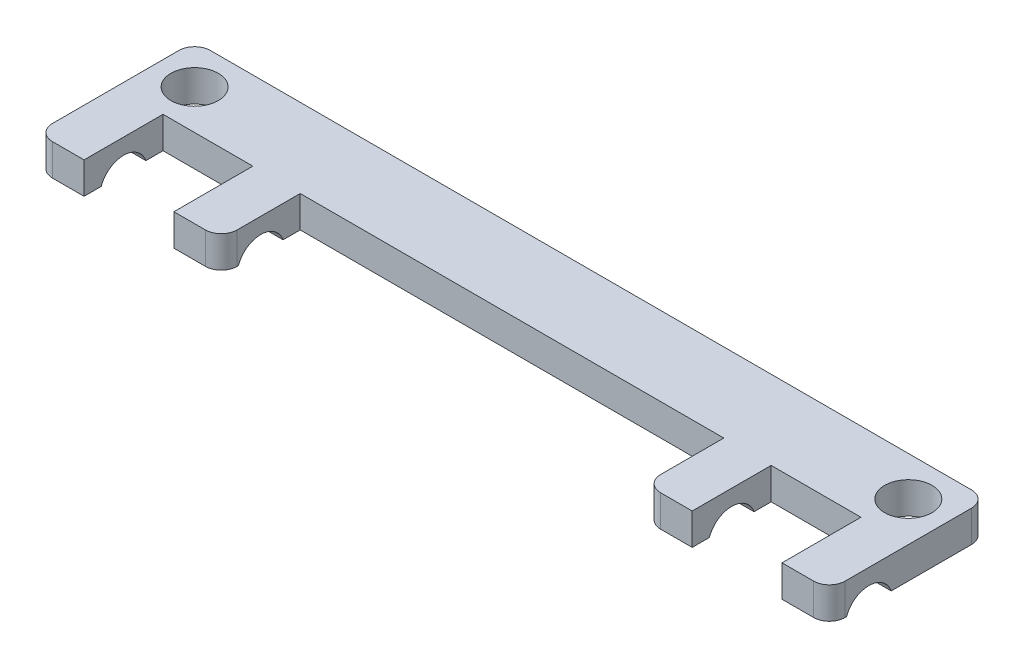
from build123d import *

# Parameters (mm, degrees)
SKETCH1_R           = 1.5
BOSS_EXTRUDE1_DEPTH = 2
SKETCH2_R           = 1.5
CUT_EXTRUDE1_DEPTH  = 55
FILLET1_R           = 1


with BuildPart() as part:
    # Sketch1 → Boss-Extrude1 (new body)
    with BuildSketch(Plane(origin=(0, 0, 0), x_dir=(1, 0, 0), z_dir=(0, 1, 0))):
        Polygon((0, 5), (0, -5), (3, -5), (3, 0), (8.68728571, 0), (8.68728571, -5), (11.68728571, -5), (11.68728571, 0), (38.51271429, 0), (38.51271429, -5), (41.51271429, -5), (41.51271429, 0), (47.2, 0), (47.2, -5), (50.2, -5), (50.2, 5), align=None)
        with Locations((2.5, 2.5)):
            Circle(SKETCH1_R, mode=Mode.SUBTRACT)
        with Locations((47.7, 2.5)):
            Circle(SKETCH1_R, mode=Mode.SUBTRACT)
    extrude(amount=BOSS_EXTRUDE1_DEPTH)

    # Sketch2 → Cut-Extrude1 (cut)
    with BuildSketch(Plane.ZY):
        with Locations((2.5, -0.5)):
            Circle(SKETCH2_R)
    extrude(amount=-CUT_EXTRUDE1_DEPTH, mode=Mode.SUBTRACT)

    # Fillet1
    fillet1_edges = [part.edges().sort_by_distance(p)[0] for p in [
        (50.2, 1, -5),
        (50.2, 1, 5),
        (38.51271429, 1, 5),
        (11.68728571, 1, 5),
        (0, 1, 5),
        (0, 1, -5),
    ]]
    fillet(fillet1_edges, radius=FILLET1_R)


solid = part.part
